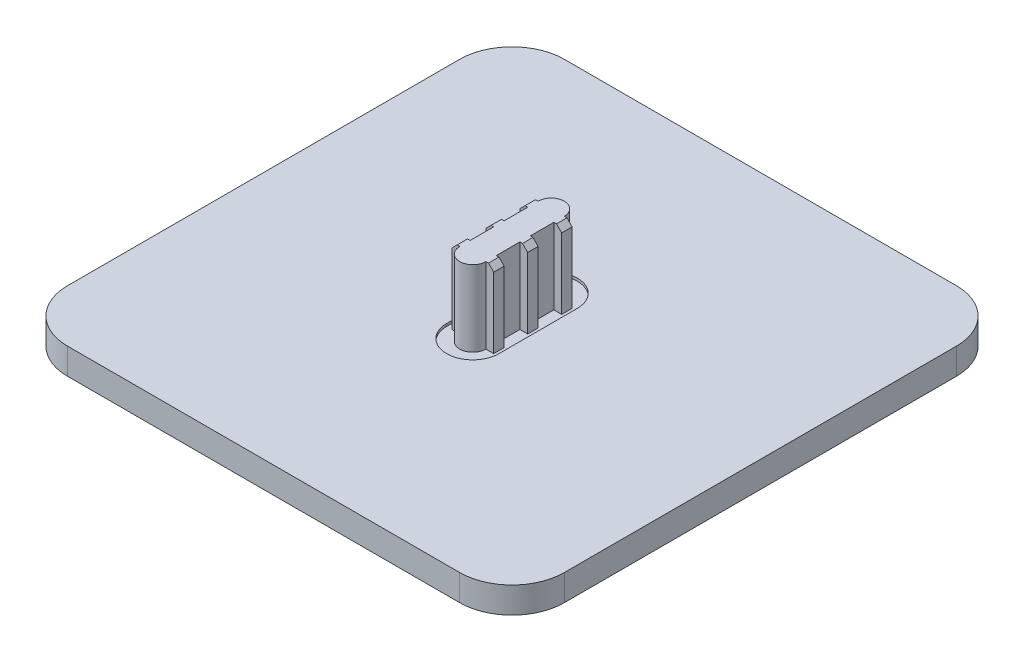
from build123d import *

# Parameters (mm, degrees)
BOSS_EXTRUDE1_DEPTH             = 5
CUT_EXTRUDE1_DEPTH              = 0.5
BOSS_EXTRUDE2_DEPTH             = 14
BOSS_EXTRUDE2_DIRECTION_2_REACH = 7
CHAMFER2_SIZE                   = 1


with BuildPart() as part:
    # Sketch1 → Boss-Extrude1 (new body)
    with BuildSketch(Plane(origin=(0, 0, 0), x_dir=(1, 0, 0), z_dir=(0, 1, 0))):
        with BuildLine():
            Line((10, 0), (85, 0))
            ThreePointArc((85, 0), (92.071067812, 2.928932188), (95, 10))
            Line((95, 10), (95, 85))
            ThreePointArc((95, 85), (92.071067812, 92.071067812), (85, 95))
            Line((85, 95), (10, 95))
            ThreePointArc((10, 95), (2.928932188, 92.071067812), (0, 85))
            Line((0, 85), (0, 10))
            ThreePointArc((0, 10), (2.928932188, 2.928932188), (10, 0))
        make_face()
    extrude(amount=BOSS_EXTRUDE1_DEPTH)

    # Sketch4 → Cut-Extrude1 (cut)
    with BuildSketch(Plane(origin=(0, 5, 0), x_dir=(1, 0, 0), z_dir=(0, 1, 0))):
        with BuildLine():
            Line((52.5, 55), (52.5, 40))
            ThreePointArc((52.5, 40), (47.5, 35), (42.5, 40))
            Line((42.5, 40), (42.5, 55))
            ThreePointArc((42.5, 55), (47.5, 60), (52.5, 55))
        make_face()
    extrude(amount=-CUT_EXTRUDE1_DEPTH, mode=Mode.SUBTRACT)

    # Sketch3 → Boss-Extrude2 (add)
    with BuildSketch(Plane(origin=(0, 5, 0), x_dir=(1, 0, 0), z_dir=(0, 1, 0))):
        with BuildLine():
            Line((45, 53.002509929), (45, 48.502509929))
            Line((45, 48.502509929), (43.5, 48.502509929))
            Line((43.5, 48.502509929), (43.5, 46.502509929))
            Line((43.5, 46.502509929), (45, 46.502509929))
            Line((45, 46.502509929), (45, 42.002509929))
            Line((45, 42.002509929), (43.5, 42.002509929))
            Line((43.5, 42.002509929), (43.5, 40.002509929))
            Line((43.5, 40.002509929), (45, 40.002509929))
            ThreePointArc((45, 40.002509929), (47.5, 37.502509929), (50, 40.002509929))
            Line((50, 40.002509929), (51.5, 40.002509929))
            Line((51.5, 40.002509929), (51.5, 42.002509929))
            Line((51.5, 42.002509929), (50, 42.002509929))
            Line((50, 42.002509929), (50, 46.502509929))
            Line((50, 46.502509929), (51.5, 46.502509929))
            Line((51.5, 46.502509929), (51.5, 48.502509929))
            Line((51.5, 48.502509929), (50, 48.502509929))
            Line((50, 48.502509929), (50, 53.002509929))
            Line((50, 53.002509929), (51.5, 53.002509929))
            Line((51.5, 53.002509929), (51.5, 55.002509929))
            Line((51.5, 55.002509929), (50, 55.002509929))
            ThreePointArc((50, 55.002509929), (47.5, 57.502509929), (45, 55.002509929))
            Line((45, 55.002509929), (43.5, 55.002509929))
            Line((43.5, 55.002509929), (43.5, 53.002509929))
            Line((43.5, 53.002509929), (45, 53.002509929))
        make_face()
    extrude(amount=BOSS_EXTRUDE2_DEPTH)

    # Sketch3 → Boss-Extrude2 direction 2 (add, up to next)
    with BuildSketch(Plane(origin=(0, 5, 0), x_dir=(1, 0, 0), z_dir=(0, 1, 0)), mode=Mode.PRIVATE) as boss_extrude2_direction_2_sk1:
        with BuildLine():
            Line((45, 53.002509929), (45, 48.502509929))
            Line((45, 48.502509929), (43.5, 48.502509929))
            Line((43.5, 48.502509929), (43.5, 46.502509929))
            Line((43.5, 46.502509929), (45, 46.502509929))
            Line((45, 46.502509929), (45, 42.002509929))
            Line((45, 42.002509929), (43.5, 42.002509929))
            Line((43.5, 42.002509929), (43.5, 40.002509929))
            Line((43.5, 40.002509929), (45, 40.002509929))
            ThreePointArc((45, 40.002509929), (47.5, 37.502509929), (50, 40.002509929))
            Line((50, 40.002509929), (51.5, 40.002509929))
            Line((51.5, 40.002509929), (51.5, 42.002509929))
            Line((51.5, 42.002509929), (50, 42.002509929))
            Line((50, 42.002509929), (50, 46.502509929))
            Line((50, 46.502509929), (51.5, 46.502509929))
            Line((51.5, 46.502509929), (51.5, 48.502509929))
            Line((51.5, 48.502509929), (50, 48.502509929))
            Line((50, 48.502509929), (50, 53.002509929))
            Line((50, 53.002509929), (51.5, 53.002509929))
            Line((51.5, 53.002509929), (51.5, 55.002509929))
            Line((51.5, 55.002509929), (50, 55.002509929))
            ThreePointArc((50, 55.002509929), (47.5, 57.502509929), (45, 55.002509929))
            Line((45, 55.002509929), (43.5, 55.002509929))
            Line((43.5, 55.002509929), (43.5, 53.002509929))
            Line((43.5, 53.002509929), (45, 53.002509929))
        make_face()
    boss_extrude2_direction_2_tool1 = extrude(boss_extrude2_direction_2_sk1.sketch, amount=-BOSS_EXTRUDE2_DIRECTION_2_REACH, mode=Mode.PRIVATE) - part.part
    add(boss_extrude2_direction_2_tool1.solids().sort_by_distance((47.5, 5, -47.50251))[0])

    # Chamfer2
    chamfer2_edges = [part.edges().sort_by_distance(p)[0] for p in [
        (43.5, 19, -47.502509929),
        (43.5, 19, -41.002509929),
        (51.5, 19, -41.002509929),
        (51.5, 19, -47.502509929),
        (51.5, 19, -54.002509929),
        (43.5, 19, -54.002509929),
    ]]
    chamfer(chamfer2_edges, length=CHAMFER2_SIZE)


solid = part.part
